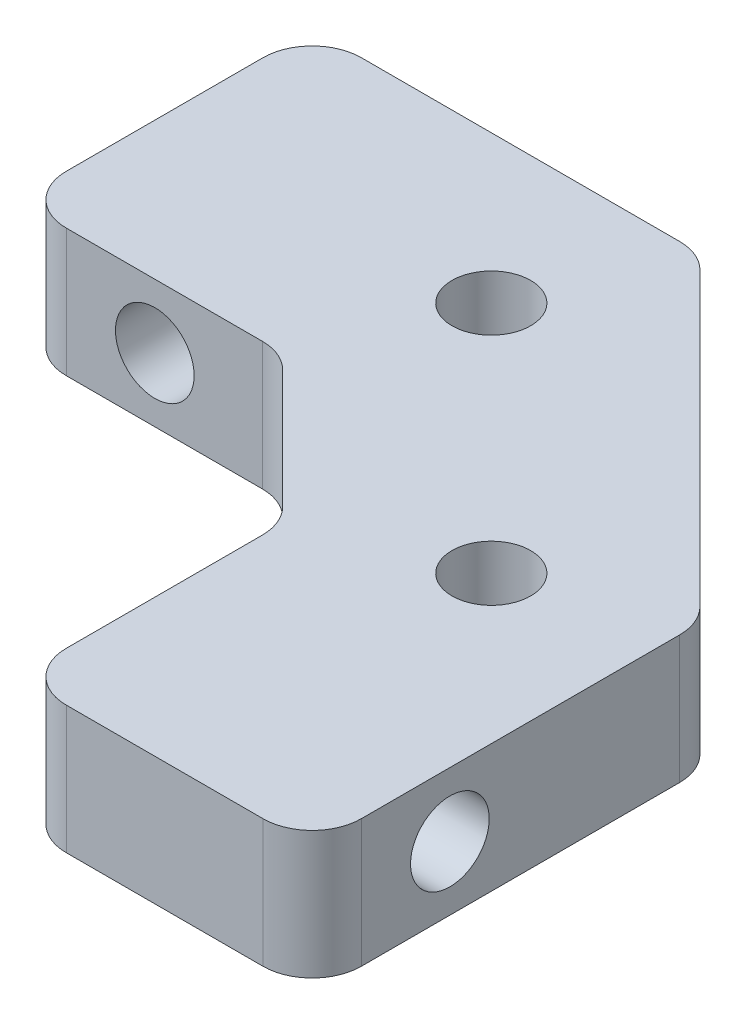
from build123d import *

# Parameters (mm, degrees)
SKETCH1_R      = 4
EXTRUDE1_DEPTH = 13
FILLET5_R      = 5
SKETCH5_R      = 4
EXTRUDE5_DEPTH = 30
SKETCH6_R      = 4
EXTRUDE6_DEPTH = 30
SKETCH8_R      = 4
EXTRUDE7_DEPTH = 30


with BuildPart() as part:
    # Sketch1 → Extrude1 (new body)
    with BuildSketch(Plane(origin=(0, 0, 0), x_dir=(1, 0, 0), z_dir=(0, 1, 0))):
        Polygon((0, -15), (-15, 0), (-42, 0), (-42, 30), (-2.573593129, 30), (30, -2.573593129), (30, -42), (0, -42), align=None)
        with Locations((-8.786796564, 15)):
            Circle(SKETCH1_R, mode=Mode.SUBTRACT)
        with Locations((15, -8.786796564)):
            Circle(SKETCH1_R, mode=Mode.SUBTRACT)
    extrude(amount=EXTRUDE1_DEPTH)

    # Fillet5
    fillet5_edges = [part.edges().sort_by_distance(p)[0] for p in [
        (-42, 6.5, 0),
        (-42, 6.5, -30),
        (-2.573593129, 6.5, -30),
        (30, 6.5, 2.573593129),
        (30, 6.5, 42),
        (0, 6.5, 42),
        (0, 6.5, 15),
        (-15, 6.5, 0),
    ]]
    fillet(fillet5_edges, radius=FILLET5_R)

    # Sketch5 → Extrude5 (cut)
    with BuildSketch(Plane(origin=(-7.5, 0, 7.5), x_dir=(0.707106781, 0, 0.707106781), z_dir=(-0.707106781, 0, 0.707106781))):
        with Locations((0, 6.5)):
            Circle(SKETCH5_R)
    extrude(amount=-EXTRUDE5_DEPTH, mode=Mode.SUBTRACT)

    # Sketch6 → Extrude6 (cut)
    with BuildSketch(Plane.XY):
        with Locations((-28, 6.5)):
            Circle(SKETCH6_R)
    extrude(amount=-EXTRUDE6_DEPTH, mode=Mode.SUBTRACT)

    # Sketch8 → Extrude7 (cut)
    with BuildSketch(Plane.ZY):
        with Locations((28, 6.5)):
            Circle(SKETCH8_R)
    extrude(amount=-EXTRUDE7_DEPTH, mode=Mode.SUBTRACT)


solid = part.part
